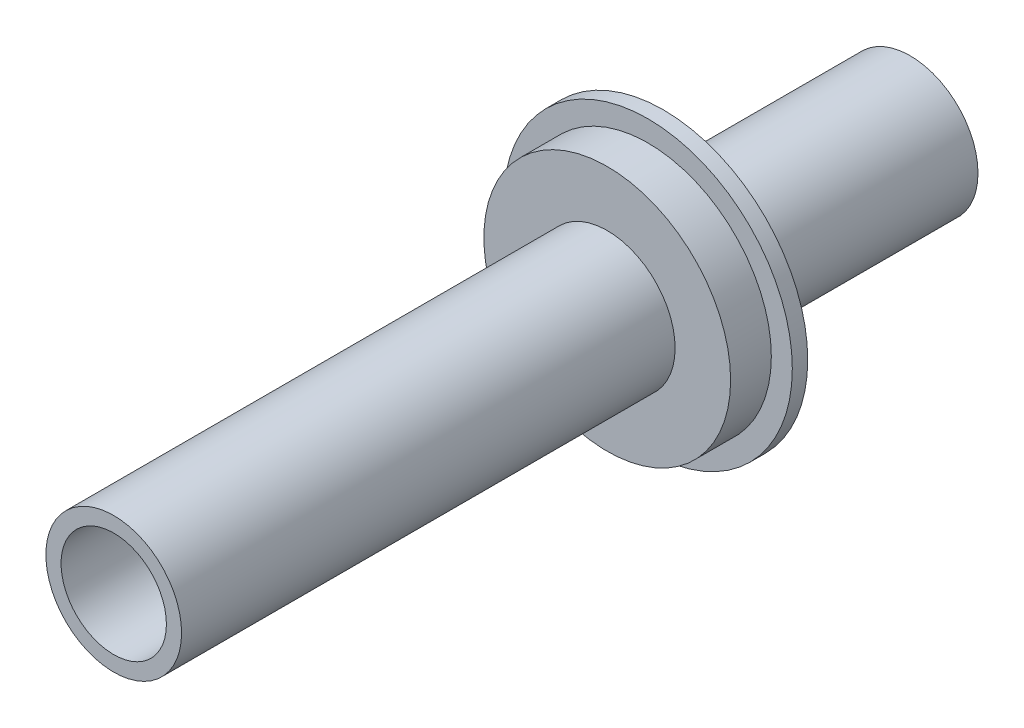
from build123d import *

# Parameters (mm, degrees)
SKETCH1_R           = 13.97
BOSS_EXTRUDE2_DEPTH = 50.8
SKETCH2_R           = 29.718
BOSS_EXTRUDE3_DEPTH = 3.175
SKETCH3_R           = 25.4
BOSS_EXTRUDE4_DEPTH = 8.382
SKETCH4_R           = 13.97
BOSS_EXTRUDE5_DEPTH = 101.6
SKETCH5_R           = 10.842824112
CUT_EXTRUDE1_DEPTH  = 101.6


with BuildPart() as part:
    # Sketch1 → Boss-Extrude2 (new body)
    with BuildSketch(Plane.XY):
        Circle(SKETCH1_R)
    extrude(amount=BOSS_EXTRUDE2_DEPTH)

    # Sketch2 → Boss-Extrude3 (add)
    with BuildSketch(Plane.XY.offset(50.8)):
        Circle(SKETCH2_R)
    extrude(amount=BOSS_EXTRUDE3_DEPTH)

    # Sketch3 → Boss-Extrude4 (add)
    with BuildSketch(Plane.XY.offset(53.975)):
        Circle(SKETCH3_R)
    extrude(amount=BOSS_EXTRUDE4_DEPTH)

    # Sketch4 → Boss-Extrude5 (add)
    with BuildSketch(Plane.XY.offset(62.357)):
        Circle(SKETCH4_R)
    extrude(amount=BOSS_EXTRUDE5_DEPTH)

    # Sketch5 → Cut-Extrude1 (cut)
    with BuildSketch(Plane.XY.offset(163.957)):
        Circle(SKETCH5_R)
    extrude(amount=-CUT_EXTRUDE1_DEPTH, mode=Mode.SUBTRACT)


solid = part.part
